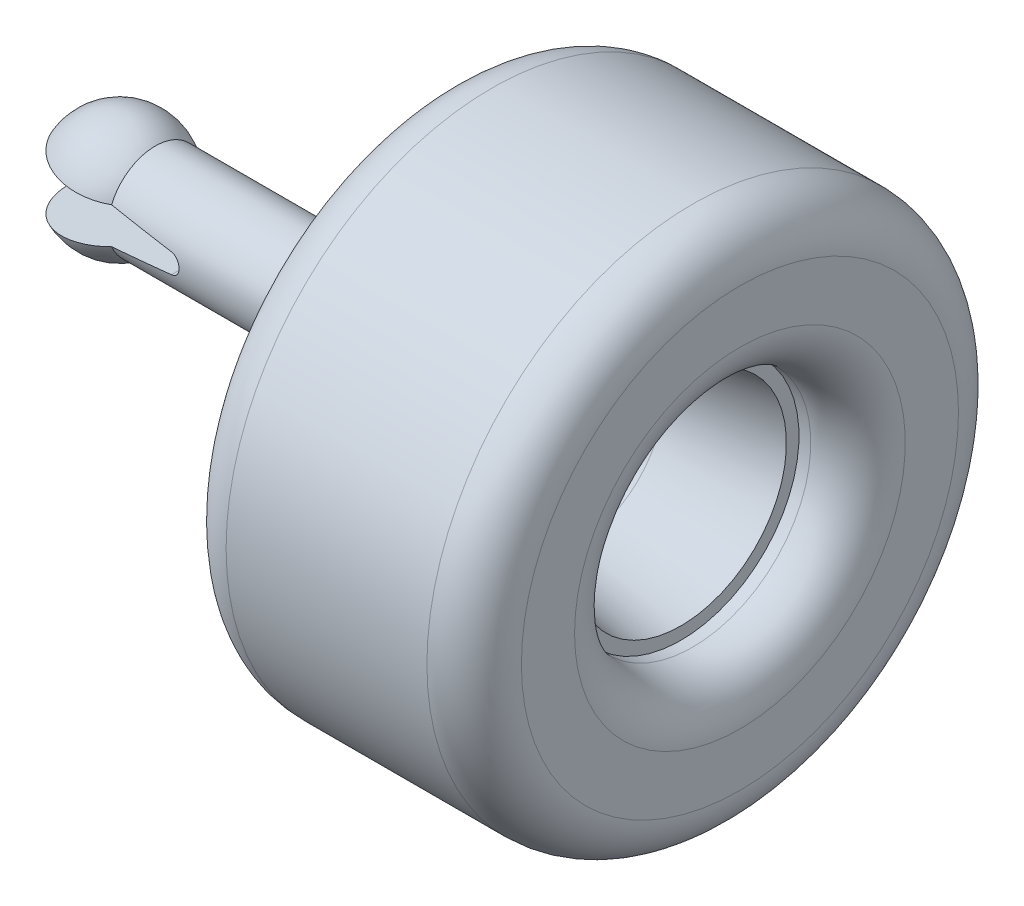
from build123d import *

# Parameters (mm, degrees)
CUT_EXTRUDE_1_DEPTH      = 46
CUT_EXTRUDE_1_DEPTH_BACK = 46


with BuildPart() as part:
    # 草圖1 → 旋轉1 (revolve)
    with BuildSketch(Plane.XY):
        with BuildLine():
            Line((6, 8), (49, 8))
            ThreePointArc((49, 8), (53.242640687, 9.757359313), (55, 14))
            Line((55, 14), (55, 37))
            ThreePointArc((55, 37), (57.343145751, 42.656854249), (63, 45))
            Line((63, 45), (97, 45))
            ThreePointArc((97, 45), (102.656854249, 42.656854249), (105, 37))
            Line((105, 37), (105, 28))
            ThreePointArc((105, 28), (102.656854249, 22.343145751), (97, 20))
            Line((97, 20), (95, 20))
            Line((95, 20), (95, 17.876303889))
            Line((95, 17.876303889), (77.395277335, 14.772116295))
            ThreePointArc((77.395277335, 14.772116295), (70.625310141, 11.709619552), (66.155739431, 5.773772537))
            Line((66.155739431, 5.773772537), (75, 5))
            Line((75, 5), (75, 0))
            Line((75, 0), (-10, 0))
            ThreePointArc((-10, 0), (-4.472135955, 8.94427191), (6, 8))
        make_face()
    revolve(axis=Axis((0, 0, 0), (1, 0, 0)))

    # 草圖2 → 除料-伸長1 (cut, two sides)
    with BuildSketch(Plane.XY) as cut_extrude_1_sk:
        with BuildLine():
            Line((-264.793827917, 38.720624717), (-8.660254038, 5))
            Line((-8.660254038, 5), (16.560866404, 1.679576502))
            ThreePointArc((16.560866404, 1.679576502), (18.033815464, 0), (16.560866404, -1.679576502))
            Line((16.560866404, -1.679576502), (-8.660254038, -5))
            Line((-8.660254038, -5), (-264.793827917, -38.720624717))
            Line((-264.793827917, -38.720624717), (-781.481308701, -38.720624717))
            Line((-781.481308701, -38.720624717), (-781.481308701, 38.720624717))
            Line((-781.481308701, 38.720624717), (-264.793827917, 38.720624717))
        make_face()
    extrude(amount=CUT_EXTRUDE_1_DEPTH, mode=Mode.SUBTRACT)
    extrude(cut_extrude_1_sk.sketch, amount=-CUT_EXTRUDE_1_DEPTH_BACK, mode=Mode.SUBTRACT)


solid = part.part
